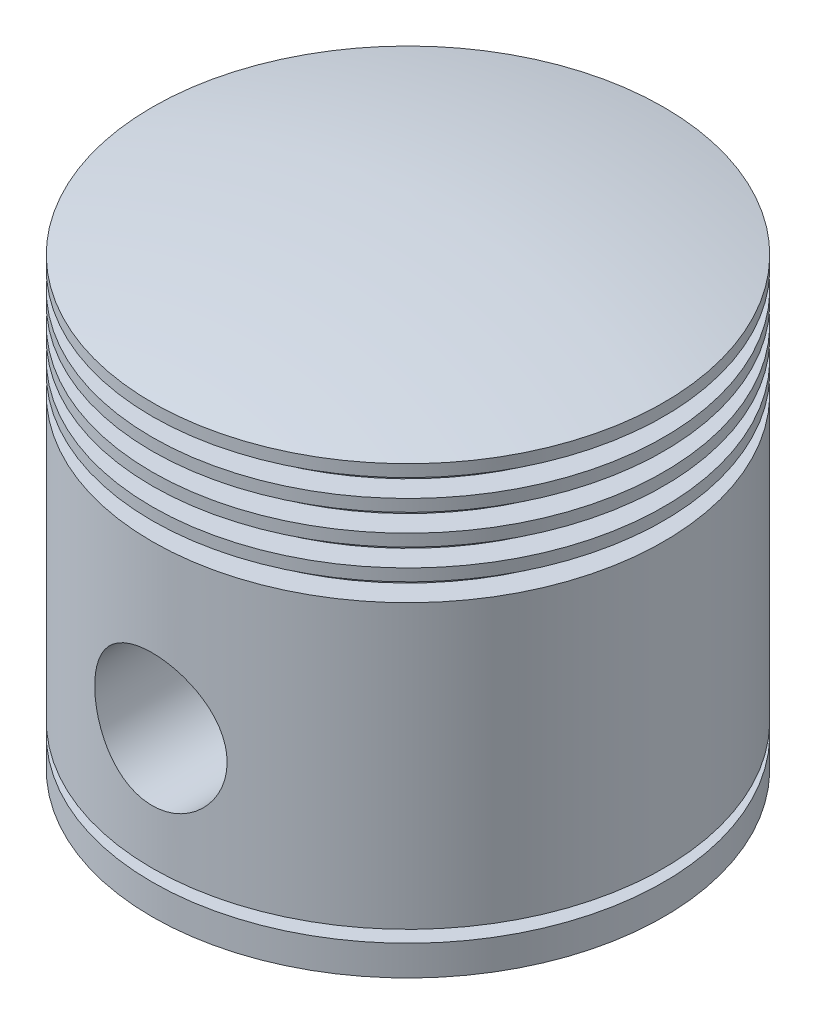
from build123d import *

# Parameters (mm, degrees)
BOSS_EXTRUDE1_REACH      = 117.008
BOSS_EXTRUDE1_END_RADIUS = 37
BOSS_EXTRUDE1_START      = 25
SKETCH2_R                = 18
BOSS_EXTRUDE2_REACH      = 117.008
BOSS_EXTRUDE2_END_RADIUS = 37
BOSS_EXTRUDE2_START      = -25
SKETCH2_2_R              = 18
CUT_EXTRUDE1_DEPTH       = 91.008333022
CUT_EXTRUDE1_DEPTH_BACK  = 91.008333022
SKETCH3_R                = 11


with BuildPart() as part:
    # Sketch1 → Revolve1 (revolve)
    with BuildSketch(Plane.XY):
        with BuildLine():
            Line((42.5, 7), (42.5, 5))
            Line((42.5, 5), (38.5, 5))
            Line((38.5, 5), (38.5, 2))
            Line((38.5, 2), (42.5, 2))
            Line((42.5, 2), (42.5, 0))
            Line((42.5, 0), (38.5, 0))
            Line((38.5, 0), (38.5, -3))
            Line((38.5, -3), (42.5, -3))
            Line((42.5, -3), (42.5, -5))
            Line((42.5, -5), (38.5, -5))
            Line((38.5, -5), (38.5, -8))
            Line((38.5, -8), (42.5, -8))
            Line((42.5, -8), (42.5, -10))
            Line((42.5, -10), (38.5, -10))
            Line((38.5, -10), (38.5, -13))
            Line((38.5, -13), (42.5, -13))
            Line((42.5, -13), (42.5, -60))
            Line((42.5, -60), (38.5, -60))
            Line((38.5, -60), (38.5, -62))
            Line((38.5, -62), (42.5, -62))
            Line((42.5, -62), (42.5, -67))
            Line((42.5, -67), (37, -67))
            Line((37, -67), (37, 0))
            Line((37, 0), (0, 0))
            Line((0, 0), (0, 11.840422459))
            ThreePointArc((0, 11.840422459), (21.387377642, 10.626417884), (42.5, 7))
        make_face()
    revolve(axis=Axis((0, 0, 0), (0, 1, 0)))

    # Boss-Extrude1: up to this cylinder (the profile starts inside it)
    boss_extrude1_end = Plane(origin=(0, -40, 0), z_dir=(0, -1, 0)) * Cylinder(BOSS_EXTRUDE1_END_RADIUS, 309.016, mode=Mode.PRIVATE)
    # Sketch2 → Boss-Extrude1 (add, up to the surface)
    with BuildSketch(Plane.XY.offset(BOSS_EXTRUDE1_START), mode=Mode.PRIVATE) as boss_extrude1_sk1:
        with Locations((0, -40)):
            Circle(SKETCH2_R)
    boss_extrude1_tool1 = extrude(boss_extrude1_sk1.sketch, amount=BOSS_EXTRUDE1_REACH, mode=Mode.PRIVATE) & boss_extrude1_end
    add(boss_extrude1_tool1.solids().sort_by_distance((0, -40, 25))[0])

    # Boss-Extrude2: up to this cylinder (the profile starts inside it)
    boss_extrude2_end = Plane(origin=(0, -40, 0), z_dir=(0, -1, 0)) * Cylinder(BOSS_EXTRUDE2_END_RADIUS, 309.016, mode=Mode.PRIVATE)
    # Sketch2_2 → Boss-Extrude2 (add, up to the surface)
    with BuildSketch(Plane.XY.offset(BOSS_EXTRUDE2_START), mode=Mode.PRIVATE) as boss_extrude2_sk1:
        with Locations((0, -40)):
            Circle(SKETCH2_2_R)
    boss_extrude2_tool1 = extrude(boss_extrude2_sk1.sketch, amount=-BOSS_EXTRUDE2_REACH, mode=Mode.PRIVATE) & boss_extrude2_end
    add(boss_extrude2_tool1.solids().sort_by_distance((0, -40, -25))[0])

    # Sketch3 → Cut-Extrude1 (cut, two sides: drawn at the far end of the back side and taken through both)
    with BuildSketch(Plane.XY.offset(-CUT_EXTRUDE1_DEPTH_BACK)):
        with Locations((0, -40)):
            Circle(SKETCH3_R)
    extrude(amount=CUT_EXTRUDE1_DEPTH + CUT_EXTRUDE1_DEPTH_BACK, mode=Mode.SUBTRACT)


solid = part.part
